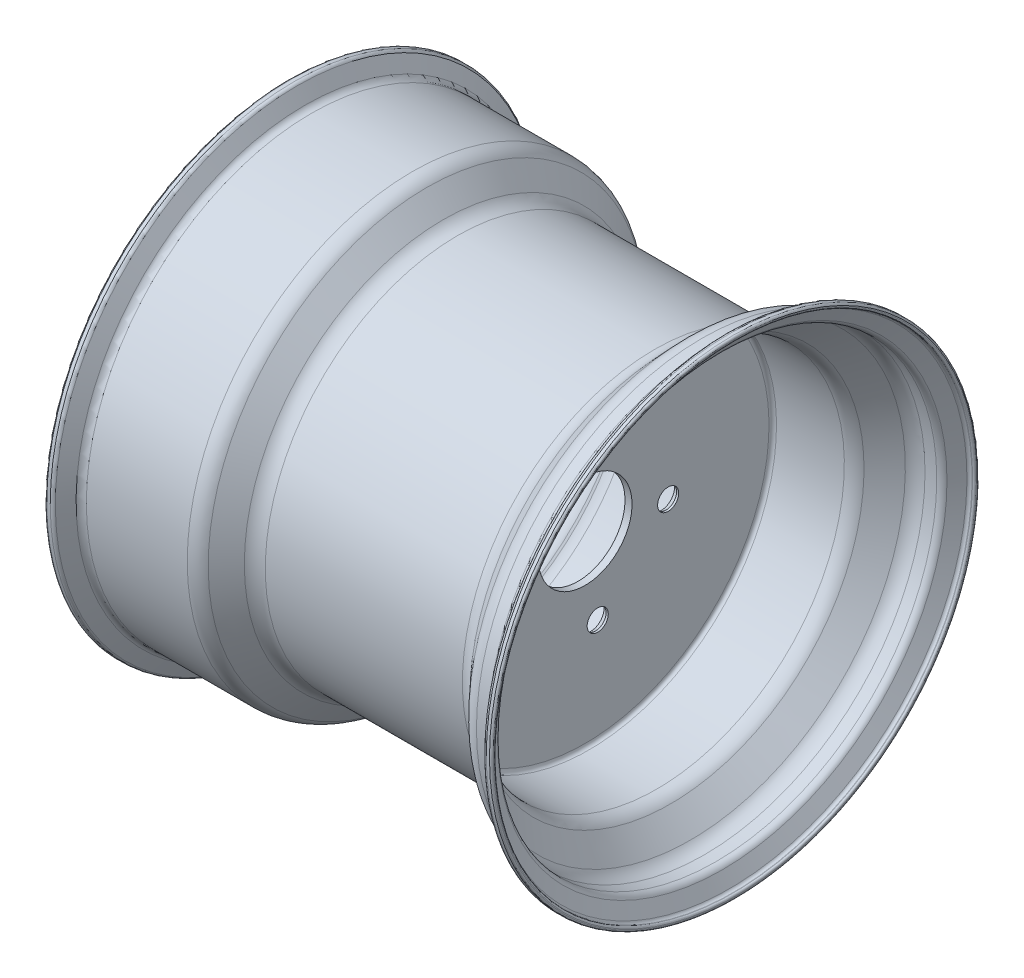
from build123d import *

# Parameters (mm, degrees)
CUT_EXTRUDE1_REACH = 108.363
SKETCH2_R          = 31.75
SKETCH2_R_2        = 7.14375
CHAMFER1_SIZE      = 1.905
CHAMFER1_SIZE2     = 3.299556788


with BuildPart() as part:
    # Sketch1 → Revolve1 (revolve)
    with BuildSketch(Plane.XY):
        with BuildLine():
            Line((-81.577137896, 130.175), (51.834853547, 130.175))
            ThreePointArc((51.834853547, 130.175), (56.898966723, 131.228337055), (61.123045558, 134.213620827))
            Line((61.123045558, 134.213620827), (74.61211719, 148.678879173))
            ThreePointArc((74.61211719, 148.678879173), (78.836196025, 151.664162945), (83.900309201, 152.7175))
            Line((83.900309201, 152.7175), (91.385251387, 152.7175))
            ThreePointArc((91.385251387, 152.7175), (93.925251387, 153.398090949), (95.784660438, 155.2575))
            Line((95.784660438, 155.2575), (100.73399562, 163.83))
            ThreePointArc((100.73399562, 163.83), (101.663700146, 164.759704526), (102.933700146, 165.1))
            Line((102.933700146, 165.1), (105.0925, 165.1))
            ThreePointArc((105.0925, 165.1), (105.990525612, 164.728025612), (106.3625, 163.83))
            Line((106.3625, 163.83), (106.3625, 163.195))
            ThreePointArc((106.3625, 163.195), (105.990525612, 162.296974388), (105.0925, 161.925))
            Line((105.0925, 161.925), (104.766787251, 161.925))
            ThreePointArc((104.766787251, 161.925), (103.496787251, 161.584704526), (102.567082725, 160.655))
            Line((102.567082725, 160.655), (97.617747542, 152.0825))
            ThreePointArc((97.617747542, 152.0825), (95.758338491, 150.223090949), (93.218338491, 149.5425))
            Line((93.218338491, 149.5425), (85.280838491, 149.5425))
            ThreePointArc((85.280838491, 149.5425), (80.216725316, 148.489162945), (75.992646481, 145.503879173))
            Line((75.992646481, 145.503879173), (62.503574849, 131.038620827))
            ThreePointArc((62.503574849, 131.038620827), (58.279496013, 128.053337055), (53.215382838, 127))
            Line((53.215382838, 127), (7.3025, 127))
            ThreePointArc((7.3025, 127), (5.506448776, 126.256051224), (4.7625, 124.46))
            Line((4.7625, 124.46), (4.7625, 0))
            Line((4.7625, 0), (0, 0))
            Line((0, 0), (0, 124.46))
            ThreePointArc((0, 124.46), (-0.743948776, 126.256051224), (-2.54, 127))
            Line((-2.54, 127), (-84.532988058, 127))
            ThreePointArc((-84.532988058, 127), (-89.874584521, 128.17796254), (-94.225283261, 131.493331144))
            Line((-94.225283261, 131.493331144), (-105.434460398, 144.731668856))
            ThreePointArc((-105.434460398, 144.731668856), (-109.785159139, 148.04703746), (-115.126755601, 149.225))
            Line((-115.126755601, 149.225), (-182.318838034, 149.225))
            ThreePointArc((-182.318838034, 149.225), (-184.858838034, 149.905590949), (-186.718247085, 151.765))
            Line((-186.718247085, 151.765), (-191.850890978, 160.655))
            ThreePointArc((-191.850890978, 160.655), (-192.780595504, 161.584704526), (-194.050595504, 161.925))
            Line((-194.050595504, 161.925), (-194.558595504, 161.925))
            ThreePointArc((-194.558595504, 161.925), (-195.456621116, 162.296974388), (-195.828595504, 163.195))
            Line((-195.828595504, 163.195), (-195.828595504, 163.83))
            ThreePointArc((-195.828595504, 163.83), (-195.456621116, 164.728025612), (-194.558595504, 165.1))
            Line((-194.558595504, 165.1), (-192.217508399, 165.1))
            ThreePointArc((-192.217508399, 165.1), (-190.947508399, 164.759704526), (-190.017803874, 163.83))
            Line((-190.017803874, 163.83), (-184.885159981, 154.94))
            ThreePointArc((-184.885159981, 154.94), (-183.025750929, 153.080590949), (-180.485750929, 152.4))
            Line((-180.485750929, 152.4), (-112.170905439, 152.4))
            ThreePointArc((-112.170905439, 152.4), (-106.829308976, 151.22203746), (-102.478610236, 147.906668856))
            Line((-102.478610236, 147.906668856), (-91.269433099, 134.668331144))
            ThreePointArc((-91.269433099, 134.668331144), (-86.918734359, 131.35296254), (-81.577137896, 130.175))
        make_face()
    revolve(axis=Axis((4.7625, 0, 0), (-1, 0, 0)))

    # Sketch2 → Cut-Extrude1 (cut, up to next)
    with BuildSketch(Plane.ZY, mode=Mode.PRIVATE) as cut_extrude1_sk1:
        Circle(SKETCH2_R)
    cut_extrude1_tool1 = extrude(cut_extrude1_sk1.sketch, amount=-CUT_EXTRUDE1_REACH, mode=Mode.PRIVATE) & part.part
    add(cut_extrude1_tool1.solids().sort_by_distance((0, 0, 0))[0], mode=Mode.SUBTRACT)
    # Sketch2 → Cut-Extrude1 (cut, up to next)
    with BuildSketch(Plane.ZY, mode=Mode.PRIVATE) as cut_extrude1_sk2:
        with Locations((-26.216720932, 50.56951524)):
            Circle(SKETCH2_R_2)
    cut_extrude1_tool2 = extrude(cut_extrude1_sk2.sketch, amount=-CUT_EXTRUDE1_REACH, mode=Mode.PRIVATE) & part.part
    add(cut_extrude1_tool2.solids().sort_by_distance((0, 50.569515, -26.216721))[0], mode=Mode.SUBTRACT)
    # Sketch2 → Cut-Extrude1 (cut, up to next)
    with BuildSketch(Plane.ZY, mode=Mode.PRIVATE) as cut_extrude1_sk3:
        with Locations((39.99305469, 40.560422884)):
            Circle(SKETCH2_R_2)
    cut_extrude1_tool3 = extrude(cut_extrude1_sk3.sketch, amount=-CUT_EXTRUDE1_REACH, mode=Mode.PRIVATE) & part.part
    add(cut_extrude1_tool3.solids().sort_by_distance((0, 40.560423, 39.993055))[0], mode=Mode.SUBTRACT)
    # Sketch2 → Cut-Extrude1 (cut, up to next)
    with BuildSketch(Plane.ZY, mode=Mode.PRIVATE) as cut_extrude1_sk4:
        with Locations((50.933788044, -25.501795299)):
            Circle(SKETCH2_R_2)
    cut_extrude1_tool4 = extrude(cut_extrude1_sk4.sketch, amount=-CUT_EXTRUDE1_REACH, mode=Mode.PRIVATE) & part.part
    add(cut_extrude1_tool4.solids().sort_by_distance((0, -25.501795, 50.933788))[0], mode=Mode.SUBTRACT)
    # Sketch2 → Cut-Extrude1 (cut, up to next)
    with BuildSketch(Plane.ZY, mode=Mode.PRIVATE) as cut_extrude1_sk5:
        with Locations((-8.514242503, -56.321399153)):
            Circle(SKETCH2_R_2)
    cut_extrude1_tool5 = extrude(cut_extrude1_sk5.sketch, amount=-CUT_EXTRUDE1_REACH, mode=Mode.PRIVATE) & part.part
    add(cut_extrude1_tool5.solids().sort_by_distance((0, -56.321399, -8.514243))[0], mode=Mode.SUBTRACT)
    # Sketch2 → Cut-Extrude1 (cut, up to next)
    with BuildSketch(Plane.ZY, mode=Mode.PRIVATE) as cut_extrude1_sk6:
        with Locations((-56.195879299, -9.306743672)):
            Circle(SKETCH2_R_2)
    cut_extrude1_tool6 = extrude(cut_extrude1_sk6.sketch, amount=-CUT_EXTRUDE1_REACH, mode=Mode.PRIVATE) & part.part
    add(cut_extrude1_tool6.solids().sort_by_distance((0, -9.306744, -56.195879))[0], mode=Mode.SUBTRACT)

    # Chamfer1
    chamfer1_edges = [part.edges().sort_by_distance(p)[0] for p in [
        (0, -25.501795299, 43.790038044),
        (0, 40.560422884, 32.84930469),
        (0, 50.56951524, -33.360470932),
        (0, -9.306743672, -63.339629299),
        (0, -56.321399153, -15.657992503),
    ]]
    chamfer1_side = [part.faces().sort_by_distance(p)[0] for p in [
        (0, -120.939739601, 0),
    ]]
    chamfer(chamfer1_edges, length=CHAMFER1_SIZE, length2=CHAMFER1_SIZE2, reference=chamfer1_side[0])


solid = part.part
